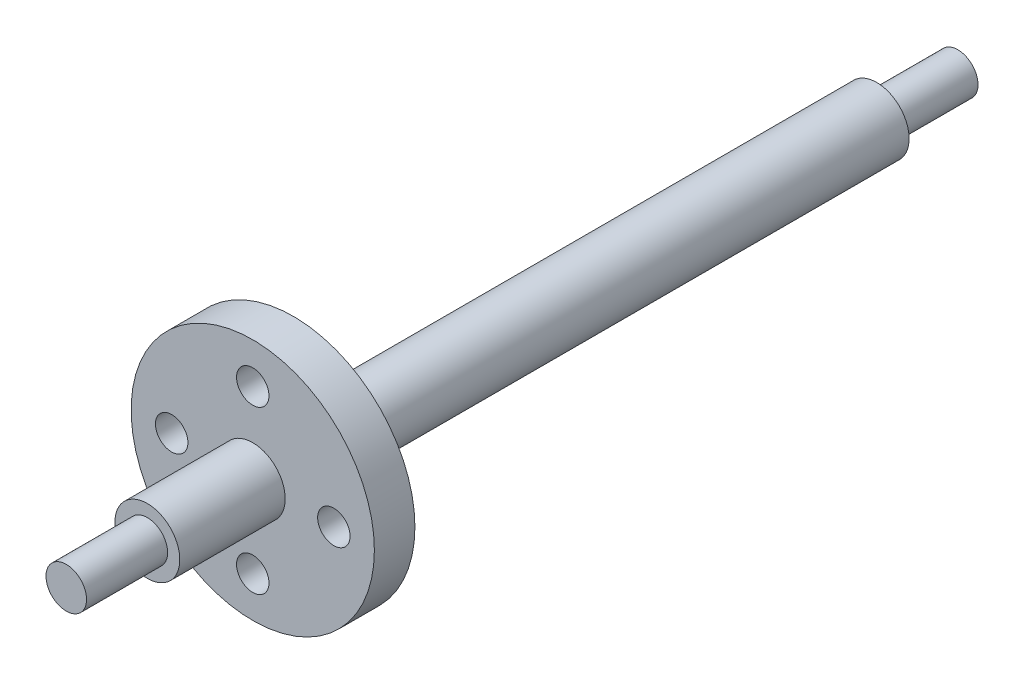
from build123d import *

# Parameters (mm, degrees)
SKETCH1_R           = 4
BOSS_EXTRUDE1_DEPTH = 109.95
SKETCH2_R           = 4
SKETCH2_R_2         = 2.5
CUT_EXTRUDE1_DEPTH  = 10
SKETCH3_R           = 15
SKETCH3_R_2         = 2
BOSS_EXTRUDE2_DEPTH = 5


with BuildPart() as part:
    # Sketch1 → Boss-Extrude1 (new body)
    with BuildSketch(Plane.XY):
        Circle(SKETCH1_R)
    extrude(amount=BOSS_EXTRUDE1_DEPTH)

    # Sketch2 → Cut-Extrude1 (cut)
    with BuildSketch(Plane(origin=(0, 0, 0), x_dir=(-1, 0, 0), z_dir=(0, 0, -1))):
        Circle(SKETCH2_R)
        Circle(SKETCH2_R_2, mode=Mode.SUBTRACT)
    cut_extrude1 = extrude(amount=-CUT_EXTRUDE1_DEPTH, mode=Mode.SUBTRACT)

    # Mirror1: Cut-Extrude1 across plane
    add(cut_extrude1.mirror(Plane.XY.offset(54.975)), mode=Mode.SUBTRACT)

    # Sketch3 → Boss-Extrude2 (add)
    with BuildSketch(Plane.XY.offset(81.95)):
        Circle(SKETCH3_R)
        with Locations((0, 10)):
            Circle(SKETCH3_R_2, mode=Mode.SUBTRACT)
        with Locations((10, 0)):
            Circle(SKETCH3_R_2, mode=Mode.SUBTRACT)
        with Locations((0, -10)):
            Circle(SKETCH3_R_2, mode=Mode.SUBTRACT)
        with Locations((-10, 0)):
            Circle(SKETCH3_R_2, mode=Mode.SUBTRACT)
    extrude(amount=BOSS_EXTRUDE2_DEPTH)


solid = part.part
